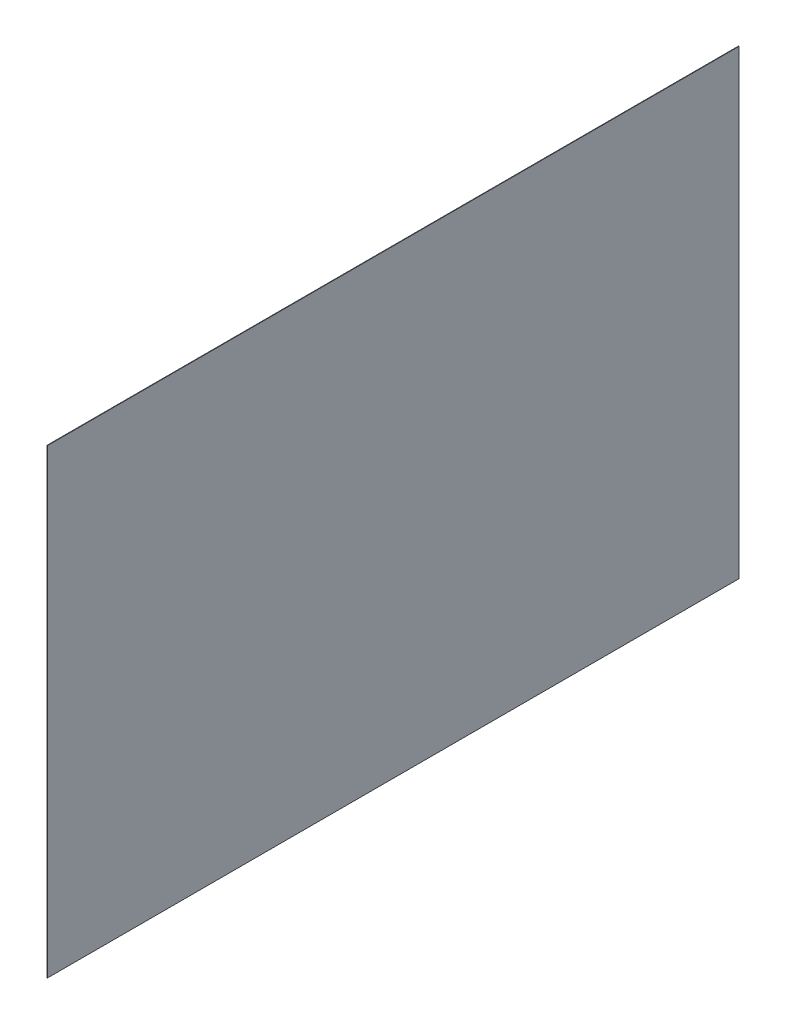
from build123d import *

# Parameters (mm, degrees)
SKETCH1_W           = 3657.6
SKETCH1_H           = 2438.4
BOSS_EXTRUDE1_DEPTH = 2.54


with BuildPart() as part:
    # Sketch1 → Boss-Extrude1 (new body)
    with BuildSketch(Plane(origin=(0, 0, 0), x_dir=(0, 0, -1), z_dir=(1, 0, 0))):
        Rectangle(SKETCH1_W, SKETCH1_H)
    extrude(amount=BOSS_EXTRUDE1_DEPTH)


solid = part.part
